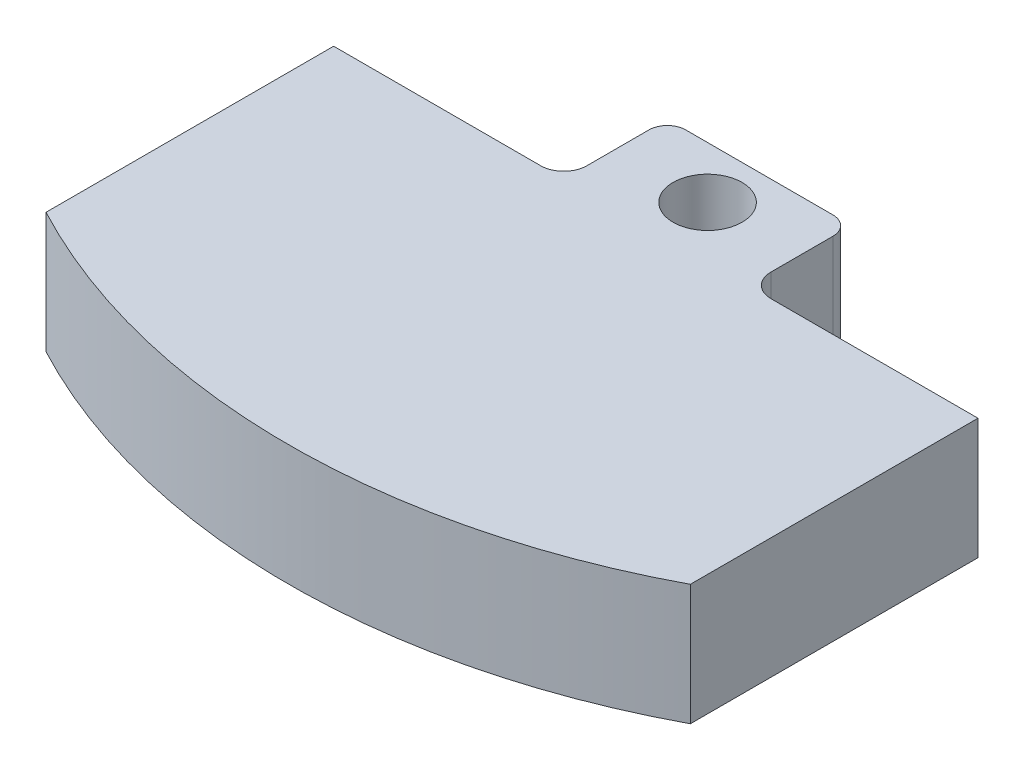
from build123d import *

# Parameters (mm, degrees)
BOSS_EXTRUDE2_DEPTH = 13.335
SKETCH10_W          = 25.4
SKETCH10_H          = 11.43
CUT_EXTRUDE1_DEPTH  = 14.335
FILLET1_R           = 2.54
FILLET2_R           = 2.032
SKETCH11_R          = 3.81
CUT_EXTRUDE2_DEPTH  = 14.335


with BuildPart() as part:
    # Sketch6 → Boss-Extrude2 (new body)
    with BuildSketch(Plane(origin=(0, 0, 0), x_dir=(1, 0, 0), z_dir=(0, 1, 0))):
        with BuildLine():
            Line((0, 0), (71.12, 0))
            Line((71.12, 0), (71.12, -43.18))
            ThreePointArc((71.12, -43.18), (35.56, -52.012400668), (0, -43.18))
            Line((0, -43.18), (0, 0))
        make_face()
    extrude(amount=BOSS_EXTRUDE2_DEPTH)

    # Sketch10 → Cut-Extrude1 (cut, through all)
    with BuildSketch(Plane(origin=(0, 13.335, 0), x_dir=(1, 0, 0), z_dir=(0, 1, 0))):
        with Locations((58.42, -5.715)):
            Rectangle(SKETCH10_W, SKETCH10_H)
        with Locations((12.7, -5.715)):
            Rectangle(SKETCH10_W, SKETCH10_H)
    extrude(amount=-CUT_EXTRUDE1_DEPTH, mode=Mode.SUBTRACT)

    # Fillet1
    fillet1_edges = [part.edges().sort_by_distance(p)[0] for p in [
        (25.4, 6.6675, 11.43),
        (45.72, 6.6675, 11.43),
    ]]
    fillet(fillet1_edges, radius=FILLET1_R)

    # Fillet2
    fillet2_edges = [part.edges().sort_by_distance(p)[0] for p in [
        (25.4, 6.6675, 0),
        (45.72, 6.6675, 0),
    ]]
    fillet(fillet2_edges, radius=FILLET2_R)

    # Sketch11 → Cut-Extrude2 (cut, through all)
    with BuildSketch(Plane.XZ):
        with Locations((35.56, 5.718912503)):
            Circle(SKETCH11_R)
    extrude(amount=-CUT_EXTRUDE2_DEPTH, mode=Mode.SUBTRACT)


solid = part.part
